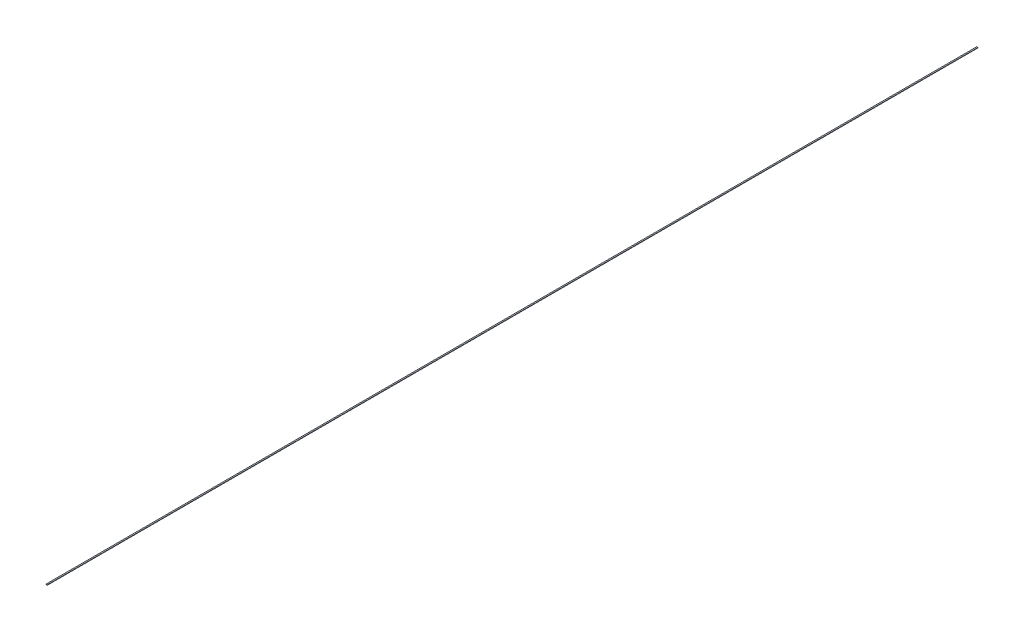
from build123d import *

# Parameters (mm, degrees)
SKETCH1_W           = 0.6
SKETCH1_H           = 0.2
BOSS_EXTRUDE1_DEPTH = 450


with BuildPart() as part:
    # Sketch1 → Boss-Extrude1 (new body)
    with BuildSketch(Plane.XY):
        with Locations((0.3, 0.1)):
            Rectangle(SKETCH1_W, SKETCH1_H)
    extrude(amount=BOSS_EXTRUDE1_DEPTH)


solid = part.part
